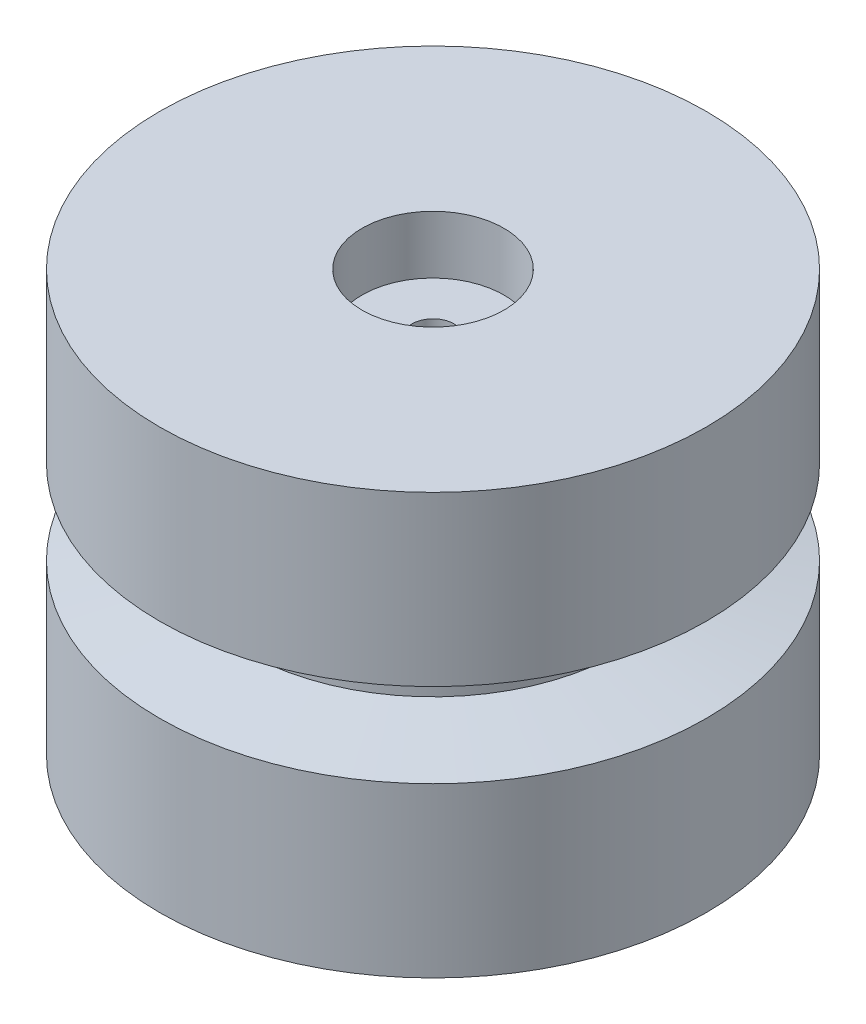
from build123d import *

# Parameters (mm, degrees)
SKETCH1_R                = 26
BOSS_EXTRUDE1_DEPTH      = 40
SKETCH2_R                = 11.25
F_608_BEARING_HOLE_DEPTH = 7.5
SKETCH3_R                = 6.75
F_624_BEARING_HOLE_DEPTH = 5.5
SKETCH4_R                = 2
CUT_EXTRUDE3_DEPTH       = 55.332310829


with BuildPart() as part:
    # Sketch1 → Boss-Extrude1 (new body)
    with BuildSketch(Plane(origin=(0, 0, 0), x_dir=(1, 0, 0), z_dir=(0, 1, 0))):
        Circle(SKETCH1_R)
    extrude(amount=BOSS_EXTRUDE1_DEPTH)

    # Sketch2 → 608_Bearing_Hole (cut)
    with BuildSketch(Plane.XZ):
        Circle(SKETCH2_R)
    extrude(amount=-F_608_BEARING_HOLE_DEPTH, mode=Mode.SUBTRACT)

    # Sketch3 → 624_Bearing_Hole (cut)
    with BuildSketch(Plane(origin=(0, 40, 0), x_dir=(1, 0, 0), z_dir=(0, 1, 0))):
        Circle(SKETCH3_R)
    extrude(amount=-F_624_BEARING_HOLE_DEPTH, mode=Mode.SUBTRACT)

    # Sketch4 → Cut-Extrude3 (cut, through all)
    with BuildSketch(Plane(origin=(0, 40, 0), x_dir=(1, 0, 0), z_dir=(0, 1, 0))):
        Circle(SKETCH4_R)
    extrude(amount=-CUT_EXTRUDE3_DEPTH, mode=Mode.SUBTRACT)

    # Sketch5 → Cut-Revolve1 (revolve, cut)
    with BuildSketch(Plane(origin=(0, 0, 0), x_dir=(0, 0, -1), z_dir=(1, 0, 0))):
        Polygon((-26, 16), (-18, 17.5), (-18, 22.5), (-26, 24), align=None)
    revolve(axis=Axis((0, 0, 0), (0, 1, 0)), mode=Mode.SUBTRACT)


solid = part.part
